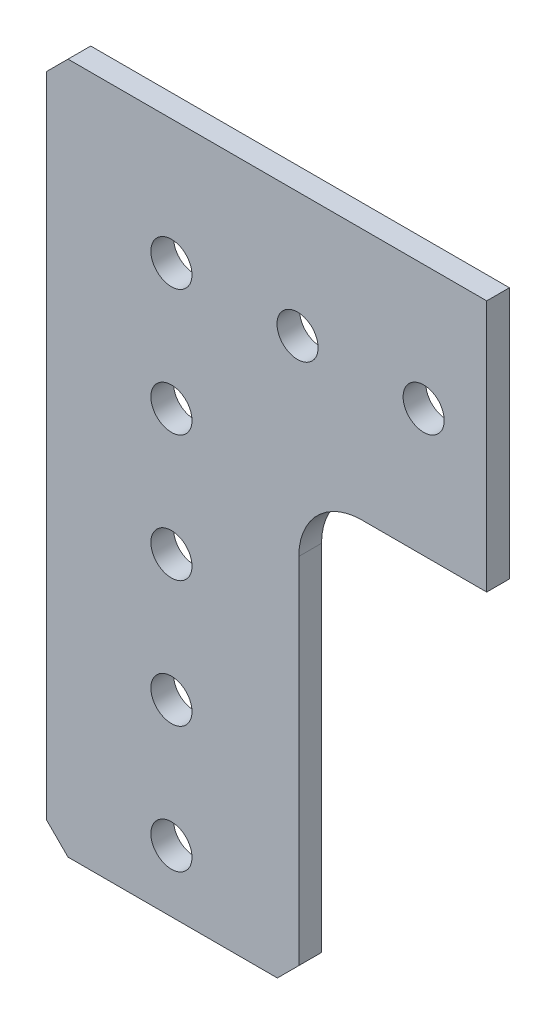
from build123d import *

# Parameters (mm, degrees)
SKETCH1_R               = 2.0701
BOSS_EXTRUDE1_DEPTH     = 2.286
SKETCH2_W               = 25.273
SKETCH2_H               = 25.4
CUT_EXTRUDE1_DEPTH      = 1
CUT_EXTRUDE1_DEPTH_BACK = 3.286


with BuildPart() as part:
    # Sketch1 → Boss-Extrude1 (new body)
    with BuildSketch(Plane(origin=(0, 0, 0), x_dir=(-1, 0, 0), z_dir=(0, 0, -1))):
        with BuildLine():
            Line((10.414, 12.573), (-54.864, 12.573))
            Line((-54.864, 12.573), (-57.023, 10.414))
            Line((-57.023, 10.414), (-57.023, -10.668))
            Line((-57.023, -10.668), (-54.864, -12.827))
            Line((-54.864, -12.827), (-19.177, -12.827))
            ThreePointArc((-19.177, -12.827), (-14.686871939, -14.686871939), (-12.827, -19.177))
            Line((-12.827, -19.177), (-12.827, -54.864))
            Line((-12.827, -54.864), (-10.668, -57.023))
            Line((-10.668, -57.023), (10.414, -57.023))
            Line((10.414, -57.023), (12.573, -54.864))
            Line((12.573, -54.864), (12.573, 10.414))
            Line((12.573, 10.414), (10.414, 12.573))
        make_face()
        with Locations((0, -50.8)):
            Circle(SKETCH1_R, mode=Mode.SUBTRACT)
        with Locations((0, -25.4)):
            Circle(SKETCH1_R, mode=Mode.SUBTRACT)
        with Locations((-38.1, 0)):
            Circle(SKETCH1_R, mode=Mode.SUBTRACT)
        with Locations((-12.7, 0)):
            Circle(SKETCH1_R, mode=Mode.SUBTRACT)
        Circle(SKETCH1_R, mode=Mode.SUBTRACT)
        with Locations((-25.4, 0)):
            Circle(SKETCH1_R, mode=Mode.SUBTRACT)
        with Locations((0, -12.7)):
            Circle(SKETCH1_R, mode=Mode.SUBTRACT)
        with Locations((0, -38.1)):
            Circle(SKETCH1_R, mode=Mode.SUBTRACT)
        with Locations((-50.8, 0)):
            Circle(SKETCH1_R, mode=Mode.SUBTRACT)
    extrude(amount=-BOSS_EXTRUDE1_DEPTH)

    # Sketch2 → Cut-Extrude1 (cut, two sides)
    with BuildSketch(Plane.XY.offset(2.286)) as cut_extrude1_sk:
        with Locations((44.3865, -0.127)):
            Rectangle(SKETCH2_W, SKETCH2_H)
    extrude(amount=CUT_EXTRUDE1_DEPTH, mode=Mode.SUBTRACT)
    extrude(cut_extrude1_sk.sketch, amount=-CUT_EXTRUDE1_DEPTH_BACK, mode=Mode.SUBTRACT)


solid = part.part
